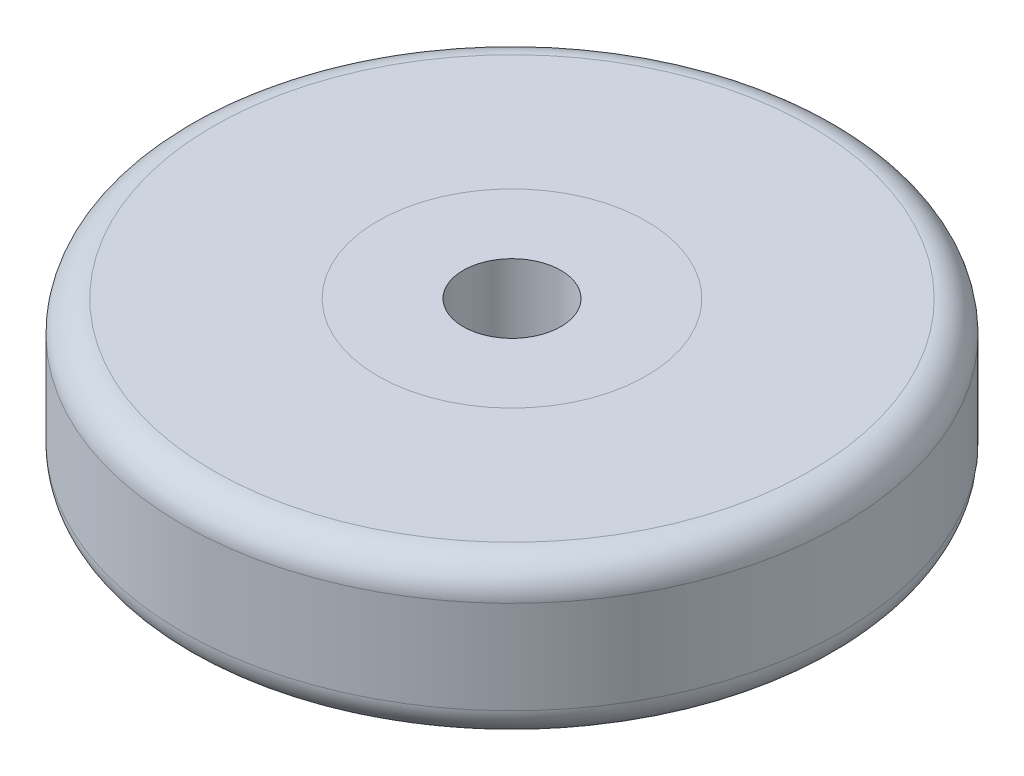
from build123d import *

# Parameters (mm, degrees)
SKETCH1_R           = 11
SKETCH1_R_2         = 4
BOSS_EXTRUDE1_DEPTH = 12.7
SKETCH2_R           = 27
SKETCH2_R_2         = 11
BOSS_EXTRUDE2_DEPTH = 12.7
FILLET1_R           = 2.54


with BuildPart() as part:
    # Sketch1 → Boss-Extrude1 (new body)
    with BuildSketch(Plane(origin=(0, 0, 0), x_dir=(1, 0, 0), z_dir=(0, 1, 0))):
        Circle(SKETCH1_R)
        Circle(SKETCH1_R_2, mode=Mode.SUBTRACT)
    extrude(amount=BOSS_EXTRUDE1_DEPTH)


with BuildPart() as body_2:
    # Sketch2 → Boss-Extrude2 (new body)
    with BuildSketch(Plane(origin=(0, 12.7, 0), x_dir=(1, 0, 0), z_dir=(0, 1, 0))):
        Circle(SKETCH2_R)
        Circle(SKETCH2_R_2, mode=Mode.SUBTRACT)
    extrude(amount=-BOSS_EXTRUDE2_DEPTH)

    # Fillet1
    fillet1_edges = [body_2.edges().sort_by_distance(p)[0] for p in [
        (-27, 12.7, 0),
        (-27, 0, 0),
    ]]
    fillet(fillet1_edges, radius=FILLET1_R)


solid = Compound([part.part, body_2.part])
